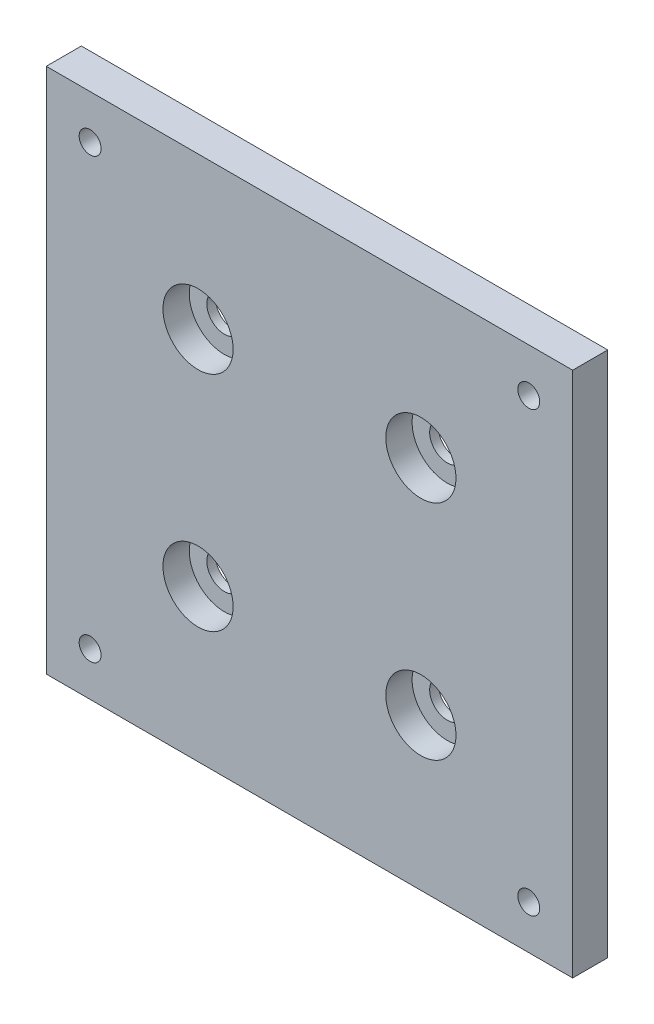
from build123d import *

# Parameters (mm, degrees)
SKETCH_1_W                = 60
SKETCH_1_H                = 60
EXTRUDE_1_DEPTH           = 4
HOLE_WIZARD_M3_1_D        = 2.5
HOLE_WIZARD_1_D           = 4
HOLE_WIZARD_1_CBORE_D     = 8
HOLE_WIZARD_1_CBORE_DEPTH = 3


with BuildPart() as part:
    # 草图1 → 凸台-拉伸1 (new body)
    with BuildSketch(Plane.XY):
        Rectangle(SKETCH_1_W, SKETCH_1_H)
    extrude(amount=EXTRUDE_1_DEPTH)

    # M3 螺纹孔1 (through all)
    with Locations(Plane(origin=(-25, 25, 4), x_dir=(1, 0, 0), z_dir=(0, 0, 1))):
        with Locations((0, 0), (50, 0), (50, -50), (0, -50)):
            Hole(HOLE_WIZARD_M3_1_D / 2)

    # 孔1 (through all)
    with Locations(Plane(origin=(-12.7, 12.7, 4), x_dir=(1, 0, 0), z_dir=(0, 0, 1))):
        with Locations((0, 0), (25.4, 0), (25.4, -25.4), (0, -25.4)):
            CounterBoreHole(HOLE_WIZARD_1_D / 2, HOLE_WIZARD_1_CBORE_D / 2, HOLE_WIZARD_1_CBORE_DEPTH)


solid = part.part
